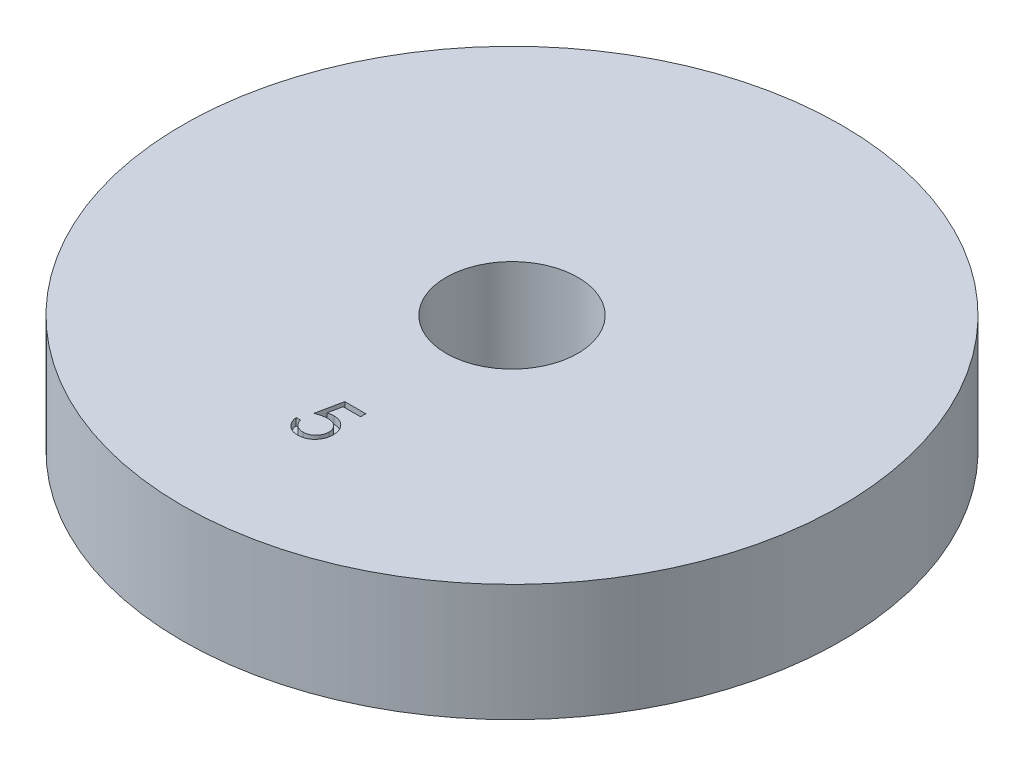
from build123d import *

# Parameters (mm, degrees)
ESQUISSE1_R             = 22.5
BOSS_EXTRU_1_DEPTH      = 8
ESQUISSE2_R             = 4.5
ENL_V_MAT_EXTRU_1_DEPTH = 8
ENL_V_MAT_EXTRU_2_DEPTH = 0.5


with BuildPart() as part:
    # Esquisse1 → Boss.-Extru.1 (new body)
    with BuildSketch(Plane(origin=(0, 0, 0), x_dir=(1, 0, 0), z_dir=(0, 1, 0))):
        Circle(ESQUISSE1_R)
    extrude(amount=BOSS_EXTRU_1_DEPTH)

    # Esquisse2 → Enlèv. mat.-Extru.1 (cut)
    with BuildSketch(Plane(origin=(0, 8, 0), x_dir=(1, 0, 0), z_dir=(0, 1, 0))):
        Circle(ESQUISSE2_R)
    extrude(amount=-ENL_V_MAT_EXTRU_1_DEPTH, mode=Mode.SUBTRACT)

    # Esquisse3 → Enlèv. mat.-Extru.2 (cut)
    with BuildSketch(Plane(origin=(0, 8, 0), x_dir=(1, 0, 0), z_dir=(0, 1, 0))):
        with BuildLine():
            Line((0.827199958, -10.808267064), (0.827199958, -11.167241423))
            Line((0.827199958, -11.167241423), (-0.36330485, -11.167241423))
            Line((-0.36330485, -11.167241423), (-0.551906612, -12.08781434))
            add(Edge.make_bspline(
                [(-0.551906612, -12.08781434), (-0.514850738, -12.077584068), (-0.443060842, -12.057764534), (-0.337100981, -12.035758764), (-0.236508778, -12.02249332), (-0.171233407, -12.020682009), (-0.139646997, -12.019805526)],
                knots=[0, 0, 0, 0, 0.000115302, 0.000223379, 0.000324431, 0.000419176, 0.000419176, 0.000419176, 0.000419176], degree=3))
            add(Edge.make_bspline(
                [(-0.139646997, -12.019805526), (-0.100563257, -12.020651461), (-0.02371486, -12.022314782), (0.088724087, -12.038286632), (0.19605698, -12.063426546), (0.29805935, -12.098547068), (0.394919901, -12.143456801), (0.485747463, -12.199556742), (0.571905376, -12.265090073), (0.65184797, -12.340435085), (0.724372278, -12.423356702), (0.788138267, -12.512514573), (0.842300858, -12.607042235), (0.885861613, -12.707842843), (0.920645947, -12.813801997), (0.943797942, -12.926034579), (0.959214651, -13.043482699), (0.960937037, -13.123787269), (0.961815343, -13.164737417)],
                knots=[0, 0, 0, 0, 0.00011719, 0.000230425, 0.000339944, 0.000447481, 0.000553499, 0.000659556, 0.000767111, 0.000877722, 0.000988528, 0.001097091, 0.001206056, 0.001314692, 0.001425996, 0.001539995, 0.001658004, 0.001780798, 0.001780798, 0.001780798, 0.001780798], degree=3))
            add(Edge.make_bspline(
                [(0.961815343, -13.164737417), (0.961150268, -13.193259637), (0.959829105, -13.249918625), (0.953110517, -13.334062825), (0.940174801, -13.416425658), (0.922807077, -13.49701805), (0.900264659, -13.575687422), (0.872975605, -13.65265895), (0.839579578, -13.727453557), (0.802948202, -13.800778952), (0.761701724, -13.870977459), (0.715923217, -13.936626446), (0.667557726, -13.998710727), (0.61551634, -14.05656446), (0.559315345, -14.109807478), (0.499635378, -14.15875576), (0.436952659, -14.20423709), (0.370297417, -14.244405285), (0.301154934, -14.281368241), (0.228526717, -14.311691779), (0.154066016, -14.338802307), (0.076701141, -14.360411834), (-0.003392672, -14.377344389), (-0.086347447, -14.38884499), (-0.171728117, -14.397221427), (-0.22960313, -14.397745784), (-0.258837702, -14.398010654)],
                knots=[0, 0, 0, 0, 8.5583e-05, 0.000170009, 0.000253005, 0.000335518, 0.000417186, 0.000498352, 0.000580291, 0.000662755, 0.000744161, 0.000824288, 0.000902692, 0.000980133, 0.001057498, 0.001134702, 0.00121156, 0.001289599, 0.001368002, 0.001446531, 0.001525481, 0.001605609, 0.001687289, 0.001770875, 0.001856759, 0.001944425, 0.001944425, 0.001944425, 0.001944425], degree=3))
            add(Edge.make_bspline(
                [(-0.258837702, -14.398010654), (-0.293711883, -14.397319816), (-0.362322713, -14.395960674), (-0.462843281, -14.381742189), (-0.559557886, -14.361378272), (-0.651687987, -14.330742002), (-0.740059251, -14.292354708), (-0.823481969, -14.243838536), (-0.904087745, -14.188859432), (-0.978599782, -14.123979079), (-1.047755895, -14.053063397), (-1.109662404, -13.976105756), (-1.164795981, -13.894376314), (-1.212273728, -13.80747816), (-1.252771749, -13.715639629), (-1.284586737, -13.618516628), (-1.310265092, -13.516616624), (-1.321128513, -13.446463114), (-1.326646196, -13.410831167)],
                knots=[0, 0, 0, 0, 0.000104552, 0.000205693, 0.000304023, 0.000400691, 0.00049644, 0.000592535, 0.000689779, 0.000788716, 0.000888377, 0.000986596, 0.001084603, 0.001183757, 0.001283279, 0.001385267, 0.001490017, 0.001598135, 0.001598135, 0.001598135, 0.001598135], degree=3))
            Line((-1.326646196, -13.410831167), (-1.012543632, -13.410831167))
            add(Edge.make_bspline(
                [(-1.012543632, -13.410831167), (-1.004815074, -13.444207619), (-0.989960358, -13.508359014), (-0.957354609, -13.598490355), (-0.917488734, -13.678809579), (-0.870084385, -13.750379162), (-0.813534355, -13.81278816), (-0.749004926, -13.868405221), (-0.676657202, -13.918580351), (-0.596263973, -13.960403118), (-0.511450894, -13.996071871), (-0.422683684, -14.019823566), (-0.332379337, -14.036524459), (-0.271300967, -14.03819622), (-0.240608535, -14.039036295)],
                knots=[0, 0, 0, 0, 0.000102709, 0.000197412, 0.000286774, 0.000371169, 0.000454082, 0.000538572, 0.000626283, 0.000717552, 0.000809994, 0.00090168, 0.00099274, 0.001084718, 0.001084718, 0.001084718, 0.001084718], degree=3))
            add(Edge.make_bspline(
                [(-0.240608535, -14.039036295), (-0.210650091, -14.038215517), (-0.151661669, -14.036599399), (-0.064850282, -14.024160386), (0.018962592, -14.005002815), (0.098949949, -13.97633296), (0.176511488, -13.941488242), (0.249685259, -13.896773166), (0.320588136, -13.845313148), (0.38701627, -13.786356517), (0.447855719, -13.721386823), (0.50161184, -13.651909429), (0.546388753, -13.577792583), (0.584122862, -13.50031943), (0.612776161, -13.418640873), (0.633217142, -13.333139698), (0.645220201, -13.243604717), (0.646871381, -13.182535408), (0.647712779, -13.151416103)],
                knots=[0, 0, 0, 0, 8.9842e-05, 0.0001769, 0.000262612, 0.000347317, 0.000431396, 0.000517249, 0.000604055, 0.000693954, 0.000783242, 0.000870748, 0.000956963, 0.001042571, 0.001128832, 0.00121607, 0.001305907, 0.001399251, 0.001399251, 0.001399251, 0.001399251], degree=3))
            add(Edge.make_bspline(
                [(0.647712779, -13.151416103), (0.647054299, -13.123340351), (0.645765419, -13.068386062), (0.635234849, -12.987986855), (0.616917877, -12.911913813), (0.591493997, -12.839799579), (0.559214489, -12.771576137), (0.519768177, -12.707173077), (0.472414779, -12.647439243), (0.41832289, -12.59234669), (0.359064849, -12.541501815), (0.293621107, -12.498157728), (0.22336118, -12.461693811), (0.14913158, -12.430225812), (0.069166682, -12.407625067), (-0.014949951, -12.390657182), (-0.104126659, -12.380841819), (-0.165097347, -12.379479931), (-0.196437862, -12.378779885)],
                knots=[0, 0, 0, 0, 8.4208e-05, 0.000164824, 0.000242709, 0.000318547, 0.000393815, 0.000468731, 0.000544614, 0.00062196, 0.000700062, 0.000778428, 0.000856831, 0.000937299, 0.001019835, 0.001105635, 0.00119452, 0.001288536, 0.001288536, 0.001288536, 0.001288536], degree=3))
            add(Edge.make_bspline(
                [(-0.196437862, -12.378779885), (-0.223566791, -12.379360476), (-0.279581146, -12.380559249), (-0.365503973, -12.389385746), (-0.455795696, -12.40362504), (-0.550110192, -12.423211288), (-0.6487307, -12.448842365), (-0.751449101, -12.479556865), (-0.858481367, -12.516278864), (-0.930599092, -12.544011078), (-0.967671837, -12.558267064)],
                knots=[0, 0, 0, 0, 8.1378e-05, 0.000168026, 0.000258858, 0.000355524, 0.000456875, 0.000564457, 0.000677092, 0.000796243, 0.000796243, 0.000796243, 0.000796243], degree=3))
            Line((-0.967671837, -12.558267064), (-0.608697478, -10.808267064))
            Line((-0.608697478, -10.808267064), (0.827199958, -10.808267064))
        make_face()
    extrude(amount=-ENL_V_MAT_EXTRU_2_DEPTH, mode=Mode.SUBTRACT)


solid = part.part
